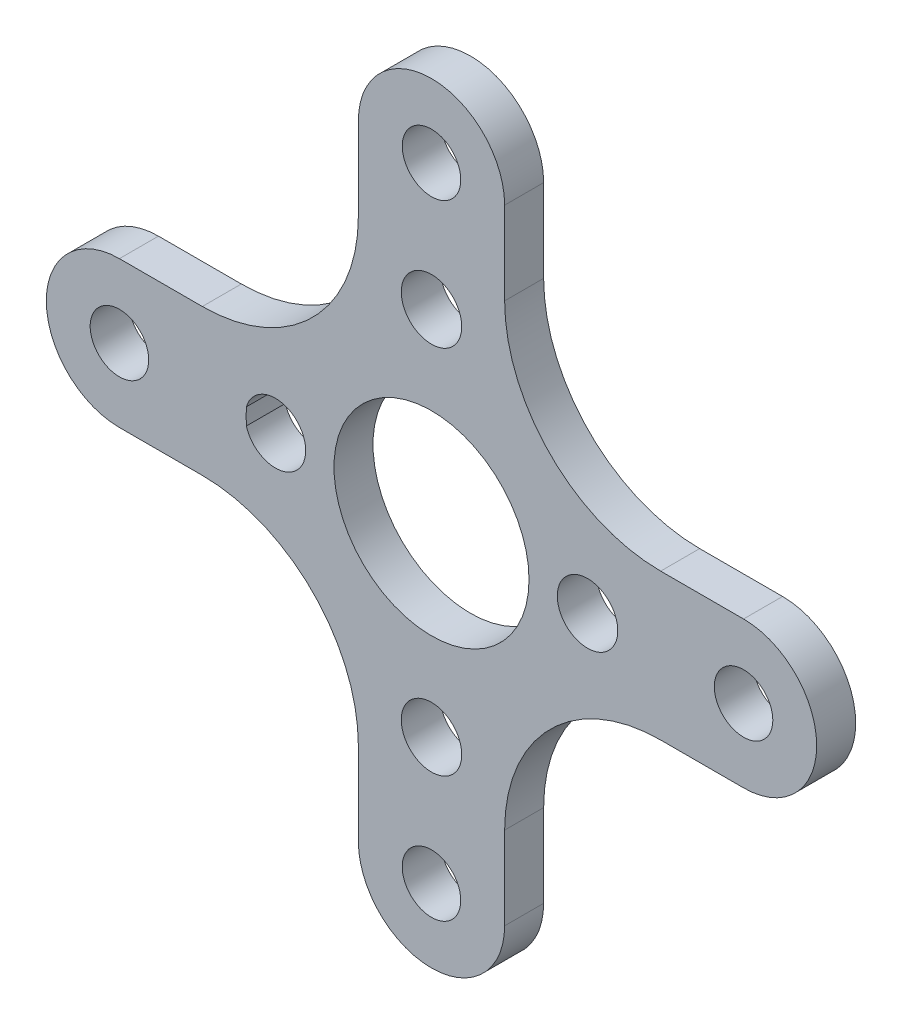
from build123d import *

# Parameters (mm, degrees)
SKETCH1_R           = 5
SKETCH1_R_2         = 1.5
BOSS_EXTRUDE1_DEPTH = 2
SKETCH3_R           = 1.55
CUT_EXTRUDE1_DEPTH  = 10


with BuildPart() as part:
    # Sketch1 → Boss-Extrude1 (new body)
    with BuildSketch(Plane.XY):
        with BuildLine():
            Line((-3.75, 16), (-3.75, 11.75))
            ThreePointArc((-3.75, 11.75), (-6.093145751, 6.093145751), (-11.75, 3.75))
            Line((-11.75, 3.75), (-16, 3.75))
            ThreePointArc((-16, 3.75), (-19.75, 0), (-16, -3.75))
            Line((-16, -3.75), (-11.75, -3.75))
            ThreePointArc((-11.75, -3.75), (-6.093145751, -6.093145751), (-3.75, -11.75))
            Line((-3.75, -11.75), (-3.75, -16))
            ThreePointArc((-3.75, -16), (0, -19.75), (3.75, -16))
            Line((3.75, -16), (3.75, -11.75))
            ThreePointArc((3.75, -11.75), (6.093145751, -6.093145751), (11.75, -3.75))
            Line((11.75, -3.75), (16, -3.75))
            ThreePointArc((16, -3.75), (19.75, 0), (16, 3.75))
            Line((16, 3.75), (11.75, 3.75))
            ThreePointArc((11.75, 3.75), (6.093145751, 6.093145751), (3.75, 11.75))
            Line((3.75, 11.75), (3.75, 16))
            ThreePointArc((3.75, 16), (0, 19.75), (-3.75, 16))
        make_face()
        Circle(SKETCH1_R, mode=Mode.SUBTRACT)
        with Locations((-16, 0)):
            Circle(SKETCH1_R_2, mode=Mode.SUBTRACT)
        with Locations((0, 16)):
            Circle(SKETCH1_R_2, mode=Mode.SUBTRACT)
        with Locations((16, 0)):
            Circle(SKETCH1_R_2, mode=Mode.SUBTRACT)
        with Locations((0, -16)):
            Circle(SKETCH1_R_2, mode=Mode.SUBTRACT)
    extrude(amount=BOSS_EXTRUDE1_DEPTH)

    # Sketch3 → Cut-Extrude1 (cut)
    with BuildSketch(Plane(origin=(0, 0, 0), x_dir=(-1, 0, 0), z_dir=(0, 0, -1))):
        with BuildLine():
            ThreePointArc((9.49046875, -0.425444362), (9.5, 0), (9.49046875, 0.425444362))
            ThreePointArc((9.49046875, 0.425444362), (6.45, 0), (9.49046875, -0.425444362))
        make_face()
        with Locations((0, 9.5)):
            Circle(SKETCH3_R)
        with Locations((0, -9.5)):
            Circle(SKETCH3_R)
        with Locations((-8, 0)):
            Circle(SKETCH3_R)
    extrude(amount=-CUT_EXTRUDE1_DEPTH, mode=Mode.SUBTRACT)


solid = part.part
